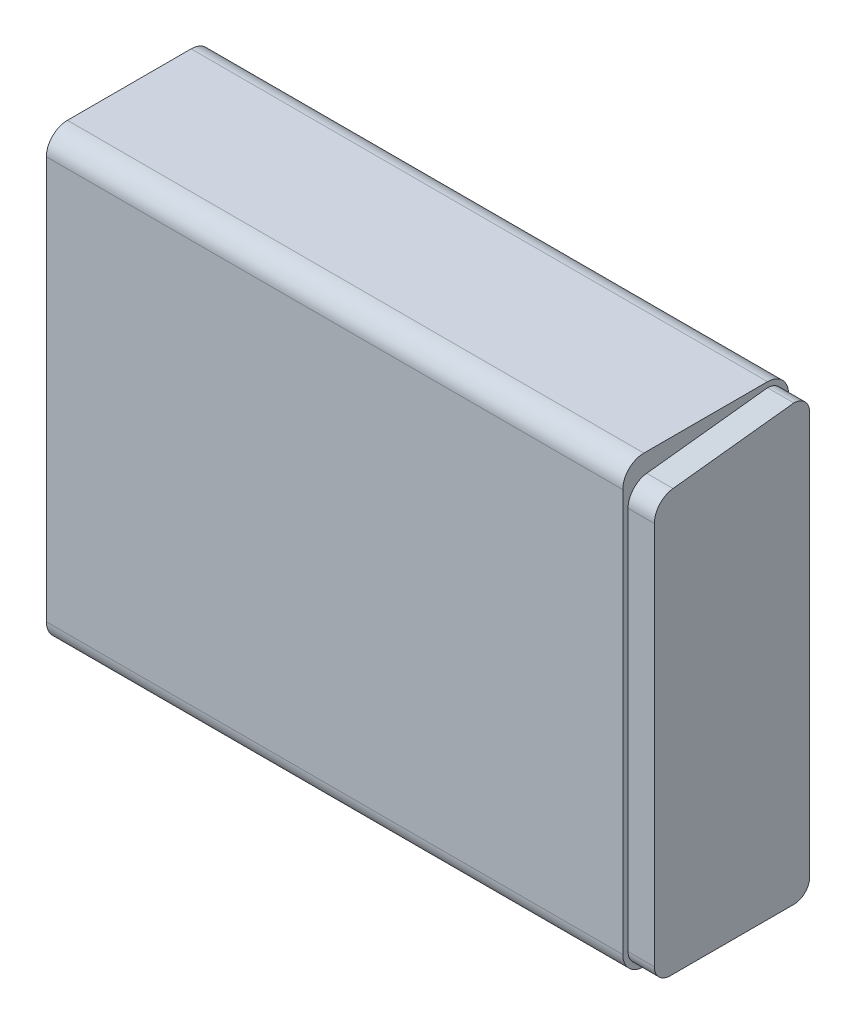
from build123d import *

# Parameters (mm, degrees)
BOSS_EXTRUDE1_DEPTH = 347.6625
BOSS_EXTRUDE2_DEPTH = 15.875


with BuildPart() as part:
    # Sketch1 → Boss-Extrude1 (new body)
    with BuildSketch(Plane(origin=(0, 0, 0), x_dir=(0, 0, -1), z_dir=(1, 0, 0))):
        with BuildLine():
            Line((12.7, 0), (87.3125, 0))
            ThreePointArc((87.3125, 0), (96.292756121, 3.719743879), (100.0125, 12.7))
            Line((100.0125, 12.7), (100.0125, 255.5875))
            ThreePointArc((100.0125, 255.5875), (96.292756121, 264.567756121), (87.3125, 268.2875))
            Line((87.3125, 268.2875), (12.7, 268.2875))
            ThreePointArc((12.7, 268.2875), (3.719743879, 264.567756121), (0, 255.5875))
            Line((0, 255.5875), (0, 12.7))
            ThreePointArc((0, 12.7), (3.719743879, 3.719743879), (12.7, 0))
        make_face()
    extrude(amount=-BOSS_EXTRUDE1_DEPTH)

    # Sketch2 → Boss-Extrude2 (add)
    with BuildSketch(Plane(origin=(0, 0, 0), x_dir=(0, 0, -1), z_dir=(1, 0, 0))):
        with BuildLine():
            Line((14.446389506, 256.863506359), (87.3125, 265.1125))
            ThreePointArc((87.3125, 265.1125), (94.047692091, 262.322692091), (96.8375, 255.5875))
            Line((96.8375, 255.5875), (96.8375, 12.7))
            ThreePointArc((96.8375, 12.7), (94.047692091, 5.964807909), (87.3125, 3.175))
            Line((87.3125, 3.175), (12.7, 3.175))
            ThreePointArc((12.7, 3.175), (5.964807909, 5.964807909), (3.175, 12.7))
            Line((3.175, 12.7), (3.175, 244.244113662))
            ThreePointArc((3.175, 244.244113662), (6.403111242, 252.704215515), (14.446389506, 256.863506359))
        make_face()
    extrude(amount=BOSS_EXTRUDE2_DEPTH)


solid = part.part
